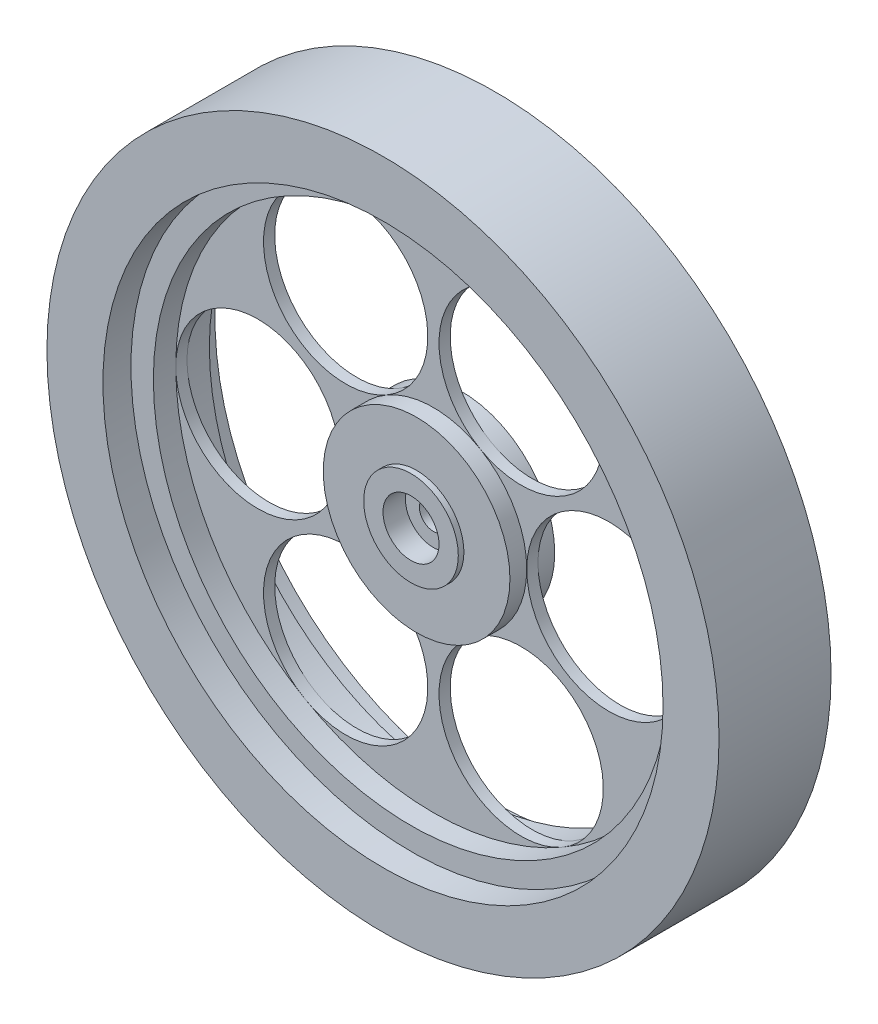
from build123d import *

# Parameters (mm, degrees)
SKETCH1_R             = 3.175
SKETCH1_R_2           = 1.5875
BOSS_EXTRUDE1_DEPTH   = 0.635
BOSS_EXTRUDE1_2_DEPTH = 0.635
BOSS_EXTRUDE1_3_DEPTH = 0.635
BOSS_EXTRUDE1_4_DEPTH = 0.635
BOSS_EXTRUDE1_5_DEPTH = 0.635
BOSS_EXTRUDE1_6_DEPTH = 0.635
BOSS_EXTRUDE1_7_DEPTH = 0.635
SKETCH1_3_R           = 31.75
SKETCH1_3_R_2         = 29.21
SKETCH1_3_R_3         = 5.363953164
SKETCH1_3_R_4         = 3.175
BOSS_EXTRUDE2_DEPTH   = 3.175
SKETCH1_4_R           = 5.363953164
BOSS_EXTRUDE4_DEPTH   = 2.54
SKETCH1_5_R           = 38.1
SKETCH1_5_R_2         = 31.75
BOSS_EXTRUDE5_DEPTH   = 6.35


with BuildPart() as part:
    # Sketch1 → Boss-Extrude1 (new, symmetric)
    with BuildSketch(Plane.XY):
        Circle(SKETCH1_R)
        Circle(SKETCH1_R_2, mode=Mode.SUBTRACT)
    extrude(amount=BOSS_EXTRUDE1_DEPTH, both=True)



with BuildPart() as body_2:
    # Sketch1 → Boss-Extrude1 2 (new, symmetric)
    with BuildSketch(Plane.XY):
        with BuildLine():
            ThreePointArc((29.21, 0), (19.896666667, -9.313333333), (10.583333333, 0))
            ThreePointArc((10.583333333, 0), (9.165435588, -5.291666555), (5.29166689, -9.165435395))
            ThreePointArc((5.29166689, -9.165435395), (18.013916746, -12.57435238), (14.604999698, -25.296602219))
            ThreePointArc((14.604999698, -25.296602219), (25.296601957, -14.605000151), (29.21, 0))
        make_face()
    extrude(amount=BOSS_EXTRUDE1_2_DEPTH, both=True)


with BuildPart() as body_3:
    # Sketch1 → Boss-Extrude1 3 (new, symmetric)
    with BuildSketch(Plane.XY):
        with BuildLine():
            ThreePointArc((5.291666671, 9.165435521), (9.165435525, 5.291666665), (10.583333333, 0))
            ThreePointArc((10.583333333, 0), (19.896666667, 9.313333333), (29.21, 0))
            ThreePointArc((29.21, 0), (25.296602069, 14.604999958), (14.605000083, 25.296601997))
            ThreePointArc((14.605000083, 25.296601997), (18.013916571, 12.574352078), (5.291666671, 9.165435521))
        make_face()
    extrude(amount=BOSS_EXTRUDE1_3_DEPTH, both=True)


with BuildPart() as body_4:
    # Sketch1 → Boss-Extrude1 4 (new, symmetric)
    with BuildSketch(Plane.XY):
        with BuildLine():
            ThreePointArc((-5.29166649, 9.165435626), (1.05e-07, 10.583333333), (5.291666671, 9.165435521))
            ThreePointArc((5.291666671, 9.165435521), (1.882750095, 21.88768549), (14.605000083, 25.296601997))
            ThreePointArc((14.605000083, 25.296601997), (8.9e-08, 29.21), (-14.604999928, 25.296602086))
            ThreePointArc((-14.604999928, 25.296602086), (-1.882750103, 21.887685503), (-5.29166649, 9.165435626))
        make_face()
    extrude(amount=BOSS_EXTRUDE1_4_DEPTH, both=True)


with BuildPart() as body_5:
    # Sketch1 → Boss-Extrude1 5 (new, symmetric)
    with BuildSketch(Plane.XY):
        with BuildLine():
            ThreePointArc((14.604999698, -25.296602219), (1.882749921, -21.887685188), (5.29166689, -9.165435395))
            ThreePointArc((5.29166689, -9.165435395), (2.57e-07, -10.583333333), (-5.291666445, -9.165435652))
            ThreePointArc((-5.291666445, -9.165435652), (-1.882750264, -21.887685783), (-14.605000442, -25.29660179))
            ThreePointArc((-14.605000442, -25.29660179), (-4.3e-07, -29.21), (14.604999698, -25.296602219))
        make_face()
    extrude(amount=BOSS_EXTRUDE1_5_DEPTH, both=True)


with BuildPart() as body_6:
    # Sketch1 → Boss-Extrude1 6 (new, symmetric)
    with BuildSketch(Plane.XY):
        with BuildLine():
            ThreePointArc((-10.583333333, 0), (-9.165435472, 5.291666755), (-5.29166649, 9.165435626))
            ThreePointArc((-5.29166649, 9.165435626), (-18.013916563, 12.574352065), (-14.604999928, 25.296602086))
            ThreePointArc((-14.604999928, 25.296602086), (-25.296602013, 14.605000055), (-29.21, 4.3e-08))
            ThreePointArc((-29.21, 4.3e-08), (-19.896666645, 9.313333333), (-10.583333333, 0))
        make_face()
    extrude(amount=BOSS_EXTRUDE1_6_DEPTH, both=True)


with BuildPart() as body_7:
    # Sketch1 → Boss-Extrude1 7 (new, symmetric)
    with BuildSketch(Plane.XY):
        with BuildLine():
            ThreePointArc((-14.605000442, -25.29660179), (-18.013916402, -12.574351785), (-5.291666445, -9.165435652))
            ThreePointArc((-5.291666445, -9.165435652), (-9.165435459, -5.291666778), (-10.583333333, 0))
            ThreePointArc((-10.583333333, 0), (-19.896666688, -9.313333333), (-29.21, 4.3e-08))
            ThreePointArc((-29.21, 4.3e-08), (-25.296602183, -14.60499976), (-14.605000442, -25.29660179))
        make_face()
    extrude(amount=BOSS_EXTRUDE1_7_DEPTH, both=True)


with BuildPart() as part_1:
    add(part.part)

    add(body_4.part)  # Boss-Extrude2 merges body 4

    add(body_7.part)  # Boss-Extrude2 merges body 7

    add(body_2.part)  # Boss-Extrude2 merges body 2
    # Sketch1_3 → Boss-Extrude2 (add, symmetric)
    # profile 1 of 2: a face of its own
    with BuildSketch(Plane.XY):
        Circle(SKETCH1_3_R)
        Circle(SKETCH1_3_R_2, mode=Mode.SUBTRACT)
    # profile 2 of 2: a face of its own
    with BuildSketch(Plane.XY):
        Circle(SKETCH1_3_R_3)
        Circle(SKETCH1_3_R_4, mode=Mode.SUBTRACT)
    extrude(amount=BOSS_EXTRUDE2_DEPTH, both=True)


    add(body_3.part)  # Boss-Extrude4 merges body 3

    add(body_5.part)  # Boss-Extrude4 merges body 5

    add(body_6.part)  # Boss-Extrude4 merges body 6
    # Sketch1_4 → Boss-Extrude4 (add, symmetric)
    with BuildSketch(Plane.XY):
        with BuildLine():
            ThreePointArc((5.29166689, -9.165435395), (9.165435588, -5.291666555), (10.583333333, 0))
            ThreePointArc((10.583333333, 0), (9.165435525, 5.291666665), (5.291666671, 9.165435521))
            ThreePointArc((5.291666671, 9.165435521), (1.05e-07, 10.583333333), (-5.29166649, 9.165435626))
            ThreePointArc((-5.29166649, 9.165435626), (-9.165435472, 5.291666755), (-10.583333333, 0))
            ThreePointArc((-10.583333333, 0), (-9.165435459, -5.291666778), (-5.291666445, -9.165435652))
            ThreePointArc((-5.291666445, -9.165435652), (2.57e-07, -10.583333333), (5.29166689, -9.165435395))
        make_face()
        Circle(SKETCH1_4_R, mode=Mode.SUBTRACT)
    extrude(amount=BOSS_EXTRUDE4_DEPTH, both=True)

    # Sketch1_5 → Boss-Extrude5 (add, symmetric)
    with BuildSketch(Plane.XY):
        Circle(SKETCH1_5_R)
        Circle(SKETCH1_5_R_2, mode=Mode.SUBTRACT)
    extrude(amount=BOSS_EXTRUDE5_DEPTH, both=True)


solid = part_1.part
